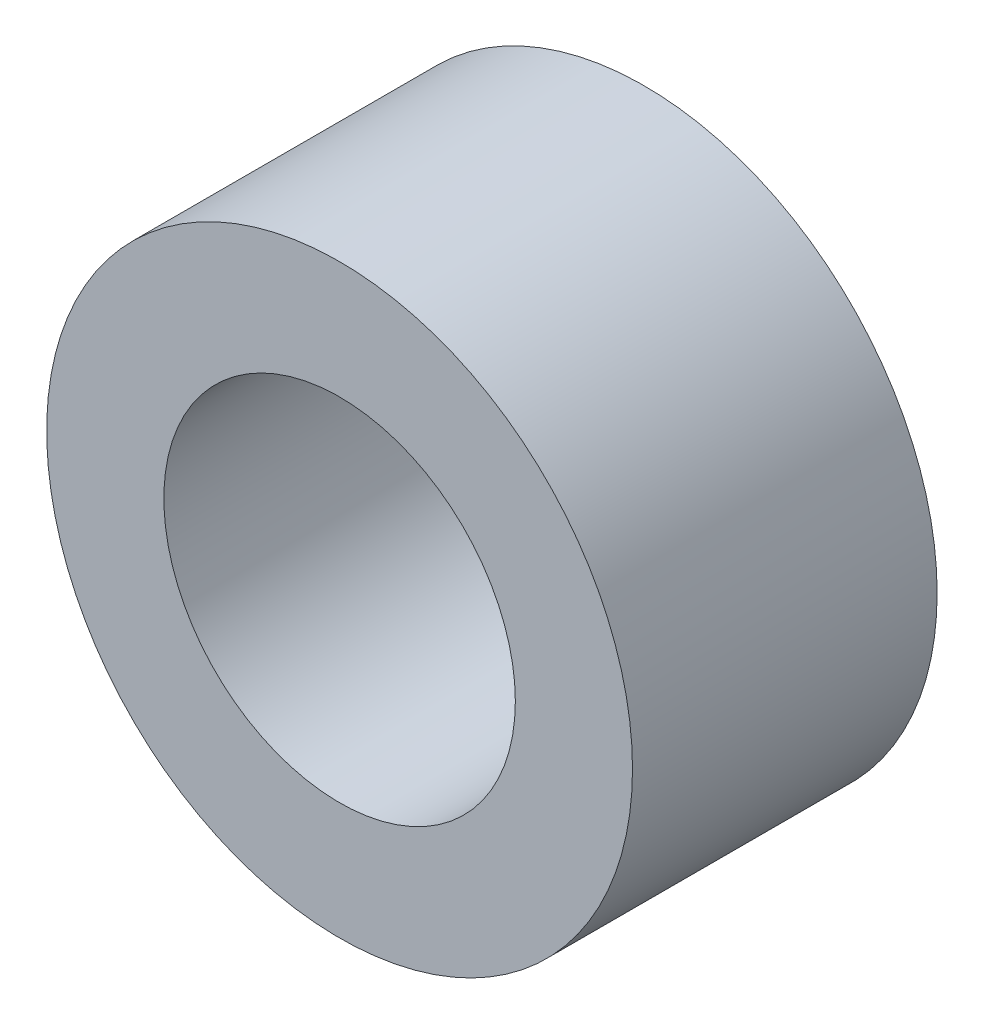
from build123d import *

# Parameters (mm, degrees)
SKETCH2_R           = 2.5
SKETCH2_R_2         = 1.5
BOSS_EXTRUDE1_DEPTH = 2.6


with BuildPart() as part:
    # Sketch2 → Boss-Extrude1 (new body)
    with BuildSketch(Plane.XY):
        Circle(SKETCH2_R)
        Circle(SKETCH2_R_2, mode=Mode.SUBTRACT)
    extrude(amount=BOSS_EXTRUDE1_DEPTH)


solid = part.part
